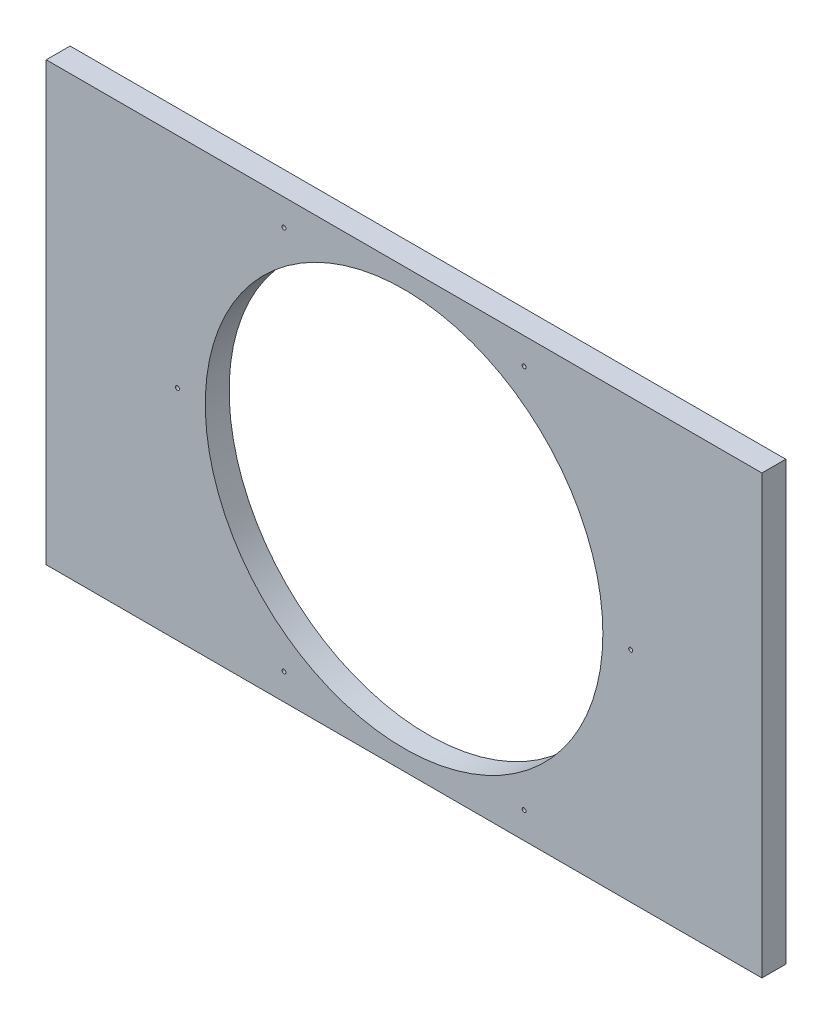
from build123d import *

# Parameters (mm, degrees)
SKETCH1_W           = 180
SKETCH1_H           = 110
BOSS_EXTRUDE1_DEPTH = 6
SKETCH2_R           = 50
CUT_EXTRUDE1_DEPTH  = 6
SKETCH4_R           = 0.5
CUT_EXTRUDE2_DEPTH  = 40


with BuildPart() as part:
    # Sketch1 → Boss-Extrude1 (new body)
    with BuildSketch(Plane.XY):
        with Locations((90, 55)):
            Rectangle(SKETCH1_W, SKETCH1_H)
    extrude(amount=BOSS_EXTRUDE1_DEPTH)

    # Sketch2 → Cut-Extrude1 (cut)
    with BuildSketch(Plane.XY):
        with Locations((90, 55)):
            Circle(SKETCH2_R)
    extrude(amount=CUT_EXTRUDE1_DEPTH, mode=Mode.SUBTRACT)

    # Sketch4 → Cut-Extrude2 (cut)
    with BuildSketch(Plane.XY):
        with Locations((59.794601939, 103.338741481)):
            Circle(SKETCH4_R)
        with Locations((120.205398061, 103.338741481)):
            Circle(SKETCH4_R)
        with Locations((147, 55)):
            Circle(SKETCH4_R)
        with Locations((120.205398061, 6.661258519)):
            Circle(SKETCH4_R)
        with Locations((59.794601939, 6.661258519)):
            Circle(SKETCH4_R)
        with Locations((33, 55)):
            Circle(SKETCH4_R)
    extrude(amount=CUT_EXTRUDE2_DEPTH, mode=Mode.SUBTRACT)


solid = part.part
